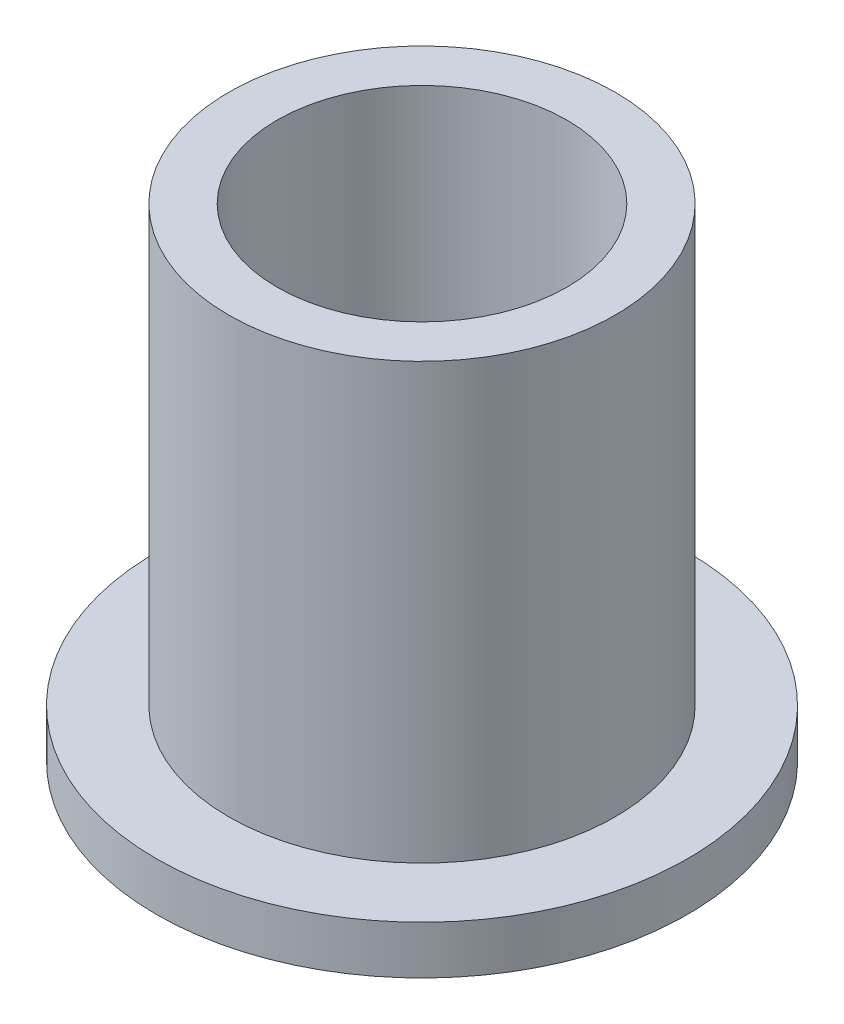
from build123d import *

# Parameters (mm, degrees)
SKETCH2_R           = 8
SKETCH2_R_2         = 6
BOSS_EXTRUDE1_DEPTH = 20
SKETCH3_R           = 11
SKETCH3_R_2         = 8
BOSS_EXTRUDE2_DEPTH = 2


with BuildPart() as part:
    # Sketch2 → Boss-Extrude1 (new body)
    with BuildSketch(Plane(origin=(0, 0, 0), x_dir=(1, 0, 0), z_dir=(0, 1, 0))):
        Circle(SKETCH2_R)
        Circle(SKETCH2_R_2, mode=Mode.SUBTRACT)
    extrude(amount=BOSS_EXTRUDE1_DEPTH)

    # Sketch3 → Boss-Extrude2 (add)
    with BuildSketch(Plane(origin=(0, 0, 0), x_dir=(1, 0, 0), z_dir=(0, 1, 0))):
        Circle(SKETCH3_R)
        Circle(SKETCH3_R_2, mode=Mode.SUBTRACT)
    extrude(amount=BOSS_EXTRUDE2_DEPTH)


solid = part.part
